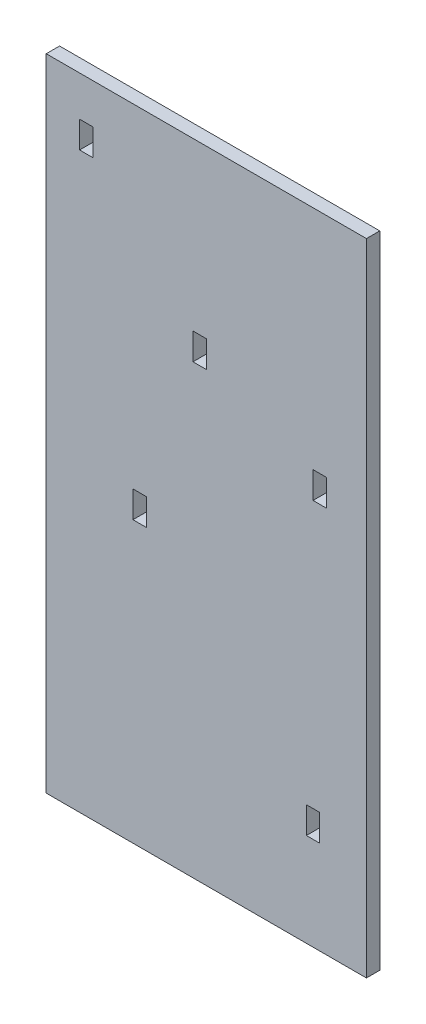
from build123d import *

# Parameters (mm, degrees)
SKETCH1_W           = 609.6
SKETCH1_H           = 1219.2
BOSS_EXTRUDE1_DEPTH = 12.7
SKETCH2_W           = 25.4
SKETCH2_H           = 50.8
CUT_EXTRUDE1_DEPTH  = 683.026656371


with BuildPart() as part:
    # Sketch1 → Boss-Extrude1 (new, symmetric)
    with BuildSketch(Plane.XY):
        Rectangle(SKETCH1_W, SKETCH1_H)
    extrude(amount=BOSS_EXTRUDE1_DEPTH, both=True)

    # Sketch2 → Cut-Extrude1 (cut, through all)
    with BuildSketch(Plane(origin=(0, 0, -12.7), x_dir=(-1, 0, 0), z_dir=(0, 0, -1))):
        with Locations((-215.9, 152.4)):
            Rectangle(SKETCH2_W, SKETCH2_H)
        with Locations((12.7, 266.7)):
            Rectangle(SKETCH2_W, SKETCH2_H)
        with Locations((228.6, 508)):
            Rectangle(SKETCH2_W, SKETCH2_H)
        with Locations((127, -50.8)):
            Rectangle(SKETCH2_W, SKETCH2_H)
        with Locations((-203.2, -406.4)):
            Rectangle(SKETCH2_W, SKETCH2_H)
    extrude(amount=-CUT_EXTRUDE1_DEPTH, mode=Mode.SUBTRACT)


solid = part.part
